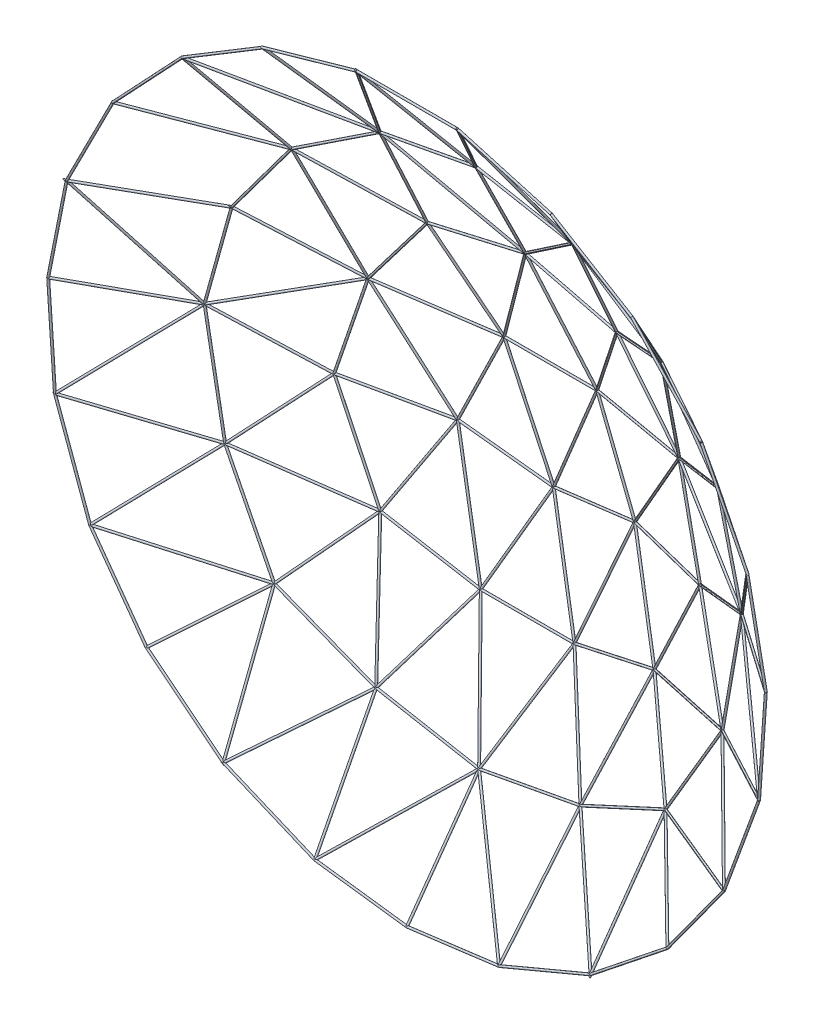
from build123d import *

# Parameters (mm, degrees)
SWEEP1_PROFILE_R  = 0.5
SWEEP2_PROFILE_R  = 0.5
SWEEP3_PROFILE_R  = 0.5
SWEEP4_PROFILE_R  = 0.5
SWEEP5_PROFILE_R  = 0.5
SWEEP6_PROFILE_R  = 0.5
SWEEP7_PROFILE_R  = 0.5
SWEEP8_PROFILE_R  = 0.5
SWEEP9_PROFILE_R  = 0.5
SWEEP10_PROFILE_R = 0.5
SWEEP11_PROFILE_R = 0.5
SWEEP12_PROFILE_R = 0.5
SWEEP13_PROFILE_R = 0.5
SWEEP14_PROFILE_R = 0.5
SWEEP15_PROFILE_R = 0.5
SWEEP16_PROFILE_R = 0.5
SWEEP17_PROFILE_R = 0.5
SWEEP18_PROFILE_R = 0.5
SWEEP19_PROFILE_R = 0.5
SWEEP20_PROFILE_R = 0.5
SWEEP21_PROFILE_R = 0.5
SWEEP22_PROFILE_R = 0.5
SWEEP23_PROFILE_R = 0.5
SWEEP24_PROFILE_R = 0.5
SWEEP25_PROFILE_R = 0.5
SWEEP26_PROFILE_R = 0.5
SWEEP27_PROFILE_R = 0.5
SWEEP28_PROFILE_R = 0.5
SWEEP29_PROFILE_R = 0.5
SWEEP30_PROFILE_R = 0.5
SWEEP31_PROFILE_R = 0.5
SWEEP32_PROFILE_R = 0.5
SWEEP33_PROFILE_R = 0.5
SWEEP34_PROFILE_R = 0.5
SWEEP35_PROFILE_R = 0.5
SWEEP36_PROFILE_R = 0.5
SWEEP37_PROFILE_R = 0.5
SWEEP38_PROFILE_R = 0.5
SWEEP39_PROFILE_R = 0.5
SWEEP40_PROFILE_R = 0.5
SWEEP41_PROFILE_R = 0.5
SWEEP42_PROFILE_R = 0.5
SWEEP43_PROFILE_R = 0.5
SWEEP44_PROFILE_R = 0.5
SWEEP45_PROFILE_R = 0.5
SWEEP46_PROFILE_R = 0.5
SWEEP47_PROFILE_R = 0.5
SWEEP48_PROFILE_R = 0.5
SWEEP49_PROFILE_R = 0.5
SWEEP50_PROFILE_R = 0.5
SWEEP51_PROFILE_R = 0.5
SWEEP52_PROFILE_R = 0.5
SWEEP53_PROFILE_R = 0.5
SWEEP54_PROFILE_R = 0.5
SWEEP55_PROFILE_R = 0.5
SWEEP56_PROFILE_R = 0.5
SWEEP57_PROFILE_R = 0.5
SWEEP58_PROFILE_R = 0.5
SWEEP59_PROFILE_R = 0.5
SWEEP60_PROFILE_R = 0.5
SWEEP61_PROFILE_R = 0.5
SWEEP62_PROFILE_R = 0.5
SWEEP63_PROFILE_R = 0.5
SWEEP64_PROFILE_R = 0.5
SWEEP65_PROFILE_R = 0.5
SWEEP66_PROFILE_R = 0.5
SWEEP67_PROFILE_R = 0.5
SWEEP68_PROFILE_R = 0.5
SWEEP69_PROFILE_R = 0.5
SWEEP70_PROFILE_R = 0.5
SWEEP71_PROFILE_R = 0.5
SWEEP72_PROFILE_R = 0.5
SWEEP73_PROFILE_R = 0.5
SWEEP74_PROFILE_R = 0.5


with BuildPart() as part:
    # Sweep1: sweep along a curve in space
    with BuildLine() as sweep1_path:
        Line((70.2, 160.3, 72.9), (24.6, 173.3, 72.9))
        Line((24.6, 173.3, 72.9), (-24.6, 173.3, 72.9))
    # Sweep1 profile (on start of the path) → Sweep1 (sweep)
    with BuildSketch(Plane(origin=(70.2, 160.3, 72.9), x_dir=(-0.2741639996416316, -0.9616829525891075, 0), z_dir=(-0.9616829525891075, 0.2741639996416316, 0))):
        Circle(SWEEP1_PROFILE_R)
    sweep(path=sweep1_path.line, transition=Transition.RIGHT)

    # Sweep2: sweep along a curve in space
    with BuildLine() as sweep2_path:
        Line((-24.6, 173.3, 72.9), (-70.2, 160.3, 72.9))
        Line((-70.2, 160.3, 72.9), (-46.9, 119.5, 39.2))
    # Sweep2 profile (on start of the path) → Sweep2 (sweep)
    with BuildSketch(Plane(origin=(-24.6, 173.3, 72.9), x_dir=(0.2741639996416316, -0.9616829525891075, 0), z_dir=(-0.9616829525891075, -0.2741639996416316, 0))):
        Circle(SWEEP2_PROFILE_R)
    sweep(path=sweep2_path.line, transition=Transition.RIGHT)

    # Sweep3: sweep along a curve in space
    with BuildLine() as sweep3_path:
        Line((-46.9, 119.5, 39.2), (-24.6, 173.3, 72.9))
        Line((-24.6, 173.3, 72.9), (0, 128.4, 39.3))
    # Sweep3 profile (on start of the path) → Sweep3 (sweep)
    with BuildSketch(Plane(origin=(-46.9, 119.5, 39.2), x_dir=(0, -0.5308482294262415, 0.8474669063243854), z_dir=(0.3314205781108869, 0.7995707220791802, 0.5008463444994122))):
        Circle(SWEEP3_PROFILE_R)
    sweep(path=sweep3_path.line, transition=Transition.RIGHT)

    # Sweep4: sweep along a curve in space
    with BuildLine() as sweep4_path:
        Line((0, 128.4, 39.3), (46.9, 119.5, 39.2))
        Line((46.9, 119.5, 39.2), (109.4, 136.6, 72.9))
    # Sweep4 profile (on start of the path) → Sweep4 (sweep)
    with BuildSketch(Plane(origin=(0, 128.4, 39.3), x_dir=(0.1864382404169094, 0.9824666826464127, 0), z_dir=(0.9824645270056661, -0.18643783135075492, -0.002094807093828891))):
        Circle(SWEEP4_PROFILE_R)
    sweep(path=sweep4_path.line, transition=Transition.RIGHT)

    # Sweep5: sweep along a curve in space
    with BuildLine() as sweep5_path:
        Line((109.4, 136.6, 72.9), (90, 90.9, 39))
        Line((90, 90.9, 39), (118.3, 52.6, 39.9))
    # Sweep5 profile (on start of the path) → Sweep5 (sweep)
    with BuildSketch(Plane(origin=(109.4, 136.6, 72.9), x_dir=(0, 0.5957737931269127, -0.8031522815899677), z_dir=(-0.322703778656751, -0.7601836435367798, -0.5638999018795807))):
        Circle(SWEEP5_PROFILE_R)
    sweep(path=sweep5_path.line, transition=Transition.RIGHT)

    # Sweep6: sweep along a curve in space
    with BuildLine() as sweep6_path:
        Line((118.3, 52.6, 39.9), (75.7, 32, 16.1))
        Line((75.7, 32, 16.1), (130.7, 6, 40.7))
    # Sweep6 profile (on start of the path) → Sweep6 (sweep)
    with BuildSketch(Plane(origin=(118.3, 52.6, 39.9), x_dir=(0.48772949518530323, 0, -0.8729948107098284), z_dir=(-0.8042662020819282, -0.38891745922271653, -0.44933182182042003))):
        Circle(SWEEP6_PROFILE_R)
    sweep(path=sweep6_path.line, transition=Transition.RIGHT)

    # Sweep7: sweep along a curve in space
    with BuildLine() as sweep7_path:
        Line((130.7, 6, 40.7), (171.3, -36, 72.9))
        Line((171.3, -36, 72.9), (154.2, -82.8, 72.9))
    # Sweep7 profile (on start of the path) → Sweep7 (sweep)
    with BuildSketch(Plane(origin=(130.7, 6, 40.7), x_dir=(-0.718988376049112, -0.695022096847475, 0), z_dir=(0.6086744462336146, -0.6296632202416703, 0.48274180218528057))):
        Circle(SWEEP7_PROFILE_R)
    sweep(path=sweep7_path.line, transition=Transition.RIGHT)

    # Sweep8: sweep along a curve in space
    with BuildLine() as sweep8_path:
        Line((154.2, -82.8, 72.9), (126.7, -120.7, 72.9))
        Line((154.2, -82.8, 72.9), (95.2, -93.3, 42.3))
    # Sweep8 profile (on start of the path) → Sweep8 (sweep)
    with BuildSketch(Plane(origin=(95.2, -93.3, 42.3), x_dir=(-0.46040499781355465, 0, 0.8877089827124094), z_dir=(0.8768342519652249, 0.1560467736548281, 0.4547648832226421))):
        Circle(SWEEP8_PROFILE_R)
    sweep(path=sweep8_path.line, transition=Transition.RIGHT)

    # Sweep9: sweep along a curve in space
    with BuildLine() as sweep9_path:
        Line((95.2, -93.3, 42.3), (66.7, -60.1, 19.2))
        Line((66.7, -60.1, 19.2), (121, -48.1, 40.4))
    # Sweep9 profile (on start of the path) → Sweep9 (sweep)
    with BuildSketch(Plane(origin=(95.2, -93.3, 42.3), x_dir=(0.7587724128401083, 0.6513558363235875, 0), z_dir=(-0.5760103446642665, 0.6710015243106539, -0.4668715425173526))):
        Circle(SWEEP9_PROFILE_R)
    sweep(path=sweep9_path.line, transition=Transition.RIGHT)

    # Sweep10: sweep along a curve in space
    with BuildLine() as sweep10_path:
        Line((121, -48.1, 40.4), (89, -13.2, 19.3))
        Line((89, -13.2, 19.3), (75.7, 32, 16.1))
    # Sweep10 profile (on start of the path) → Sweep10 (sweep)
    with BuildSketch(Plane(origin=(121, -48.1, 40.4), x_dir=(0.7370664686334993, 0.6758202577728363, 0), z_dir=(-0.6173029703937462, 0.6732460520856792, -0.4070341461033763))):
        Circle(SWEEP10_PROFILE_R)
    sweep(path=sweep10_path.line, transition=Transition.RIGHT)

    # Sweep11: sweep along a curve in space
    with BuildLine() as sweep11_path:
        Line((75.7, 32, 16.1), (43.1, -16.8, 5.1))
        Line((43.1, -16.8, 5.1), (66.7, -60.1, 19.2))
    # Sweep11 profile (on start of the path) → Sweep11 (sweep)
    with BuildSketch(Plane(origin=(75.7, 32, 16.1), x_dir=(-0.8315256316094289, 0.5554863850505611, 0), z_dir=(-0.5459786384308439, -0.8172931765467847, -0.18422592094292278))):
        Circle(SWEEP11_PROFILE_R)
    sweep(path=sweep11_path.line, transition=Transition.RIGHT)

    # Sweep12: sweep along a curve in space
    with BuildLine() as sweep12_path:
        Line((66.7, -60.1, 19.2), (22.8, -73.6, 14.2))
        Line((22.8, -73.6, 14.2), (49.7, -116.5, 38.2))
    # Sweep12 profile (on start of the path) → Sweep12 (sweep)
    with BuildSketch(Plane(origin=(66.7, -60.1, 19.2), x_dir=(0.293932846991094, -0.9558260728080765, 0), z_dir=(-0.9502119984175122, -0.2922064232035629, -0.10822460118650479))):
        Circle(SWEEP12_PROFILE_R)
    sweep(path=sweep12_path.line, transition=Transition.RIGHT)

    # Sweep13: sweep along a curve in space
    with BuildLine() as sweep13_path:
        Line((49.7, -116.5, 38.2), (44.8, -169.2, 72.9))
        Line((44.8, -169.2, 72.9), (0, -175, 72.9))
    # Sweep13 profile (on start of the path) → Sweep13 (sweep)
    with BuildSketch(Plane(origin=(49.7, -116.5, 38.2), x_dir=(0, -0.5499366446305571, -0.8352063738337275), z_dir=(-0.07742365604684504, -0.8326993211568832, 0.5482858907807184))):
        Circle(SWEEP13_PROFILE_R)
    sweep(path=sweep13_path.line, transition=Transition.RIGHT)

    # Sweep14: sweep along a curve in space
    with BuildLine() as sweep14_path:
        Line((0, -175, 72.9), (0, -126.1, 37.8))
        Line((0, -126.1, 37.8), (49.7, -116.5, 38.2))
    # Sweep14 profile (on start of the path) → Sweep14 (sweep)
    with BuildSketch(Plane(origin=(0, -175, 72.9), x_dir=(0, 0.5831224527684974, 0.8123842718056842), z_dir=(0, 0.8123842718056842, -0.5831224527684974))):
        Circle(SWEEP14_PROFILE_R)
    sweep(path=sweep14_path.line, transition=Transition.RIGHT)

    # Sweep15: sweep along a curve in space
    with BuildLine() as sweep15_path:
        Line((49.7, -116.5, 38.2), (89.3, -150.5, 72.9))
        Line((89.3, -150.5, 72.9), (95.2, -93.3, 42.3))
    # Sweep15 profile (on start of the path) → Sweep15 (sweep)
    with BuildSketch(Plane(origin=(49.7, -116.5, 38.2), x_dir=(-0.6590422824772967, 0, 0.7521058900893645), z_dir=(0.6318232837371024, -0.5424745365419565, 0.5536431299413499))):
        Circle(SWEEP15_PROFILE_R)
    sweep(path=sweep15_path.line, transition=Transition.RIGHT)

    # Sweep16: sweep along a curve in space
    with BuildLine() as sweep16_path:
        Line((95.2, -93.3, 42.3), (49.7, -116.5, 38.2))
        Line((49.7, -116.5, 38.2), (66.7, -60.1, 19.2))
    # Sweep16 profile (on start of the path) → Sweep16 (sweep)
    with BuildSketch(Plane(origin=(95.2, -93.3, 42.3), x_dir=(0.4542483901231364, -0.890875075457013, 0), z_dir=(-0.8880183239286837, -0.4527917607724278, -0.08001923358478251))):
        Circle(SWEEP16_PROFILE_R)
    sweep(path=sweep16_path.line, transition=Transition.RIGHT)

    # Sweep17: sweep along a curve in space
    with BuildLine() as sweep17_path:
        Line((66.7, -60.1, 19.2), (89, -13.2, 19.3))
        Line((89, -13.2, 19.3), (130.7, 6, 40.7))
    # Sweep17 profile (on start of the path) → Sweep17 (sweep)
    with BuildSketch(Plane(origin=(66.7, -60.1, 19.2), x_dir=(0.9031095214958049, -0.4294102842080268, 0), z_dir=(0.429409488091949, 0.9031078471530225, 0.0019256030856141476))):
        Circle(SWEEP17_PROFILE_R)
    sweep(path=sweep17_path.line, transition=Transition.RIGHT)

    # Sweep18: sweep along a curve in space
    with BuildLine() as sweep18_path:
        Line((130.7, 6, 40.7), (118.3, 52.6, 39.9))
        Line((130.7, 6, 40.7), (121, -48.1, 40.4))
    # Sweep18 profile (on start of the path) → Sweep18 (sweep)
    with BuildSketch(Plane(origin=(121, -48.1, 40.4), x_dir=(0.9843036385612428, -0.17648327715423429, 0), z_dir=(0.1764806482787259, 0.9842889764823765, 0.005458164379754477))):
        Circle(SWEEP18_PROFILE_R)
    sweep(path=sweep18_path.line, transition=Transition.RIGHT)

    # Sweep19: sweep along a curve in space
    with BuildLine() as sweep19_path:
        Line((121, -48.1, 40.4), (171.3, -36, 72.9))
        Line((171.3, -36, 72.9), (174.6, 11.2, 72.9))
    # Sweep19 profile (on start of the path) → Sweep19 (sweep)
    with BuildSketch(Plane(origin=(121, -48.1, 40.4), x_dir=(-0.5426972625369433, 0, 0.8399283786341), z_dir=(0.8232913130617963, 0.19804820850989518, 0.531947667485256))):
        Circle(SWEEP19_PROFILE_R)
    sweep(path=sweep19_path.line, transition=Transition.RIGHT)

    # Sweep20: sweep along a curve in space
    with BuildLine() as sweep20_path:
        Line((174.6, 11.2, 72.9), (130.7, 6, 40.7))
        Line((130.7, 6, 40.7), (165.6, 56.6, 72.9))
    # Sweep20 profile (on start of the path) → Sweep20 (sweep)
    with BuildSketch(Plane(origin=(174.6, 11.2, 72.9), x_dir=(0.5914432899526433, 0, -0.8063465971714606), z_dir=(-0.8026935621323736, -0.09507987524119235, -0.5887638428396912))):
        Circle(SWEEP20_PROFILE_R)
    sweep(path=sweep20_path.line, transition=Transition.RIGHT)

    # Sweep21: sweep along a curve in space
    with BuildLine() as sweep21_path:
        Line((121, -48.1, 40.4), (95.2, -93.3, 42.3))
        Line((95.2, -93.3, 42.3), (126.7, -120.7, 72.9))
    # Sweep21 profile (on start of the path) → Sweep21 (sweep)
    with BuildSketch(Plane(origin=(121, -48.1, 40.4), x_dir=(-0.868479525327704, 0.49572503879324686, 0), z_dir=(-0.4953950292338643, -0.8679013690453748, 0.0364825796722613))):
        Circle(SWEEP21_PROFILE_R)
    sweep(path=sweep21_path.line, transition=Transition.RIGHT)

    # Sweep22: sweep along a curve in space
    with BuildLine() as sweep22_path:
        Line((126.7, -120.7, 72.9), (89.3, -150.5, 72.9))
        Line((89.3, -150.5, 72.9), (44.8, -169.2, 72.9))
    # Sweep22 profile (on start of the path) → Sweep22 (sweep)
    with BuildSketch(Plane(origin=(126.7, -120.7, 72.9), x_dir=(0.6231637359515897, -0.7820914001540085, 0), z_dir=(-0.7820914001540085, -0.6231637359515897, 0))):
        Circle(SWEEP22_PROFILE_R)
    sweep(path=sweep22_path.line, transition=Transition.RIGHT)

    # Sweep23: sweep along a curve in space
    with BuildLine() as sweep23_path:
        Line((44.8, -169.2, 72.9), (0, -126.1, 37.8))
        Line((0, -126.1, 37.8), (22.8, -73.6, 14.2))
    # Sweep23 profile (on start of the path) → Sweep23 (sweep)
    with BuildSketch(Plane(origin=(44.8, -169.2, 72.9), x_dir=(-0.6933015736679883, -0.7206475754135936, 0), z_dir=(-0.6275309969389807, 0.6037184367872783, -0.4916593301910319))):
        Circle(SWEEP23_PROFILE_R)
    sweep(path=sweep23_path.line, transition=Transition.RIGHT)

    # Sweep24: sweep along a curve in space
    with BuildLine() as sweep24_path:
        Line((22.8, -73.6, 14.2), (-22.8, -73.6, 14.2))
        Line((-22.8, -73.6, 14.2), (-43.1, -16.8, 5.1))
    # Sweep24 profile (on start of the path) → Sweep24 (sweep)
    with BuildSketch(Plane(origin=(22.8, -73.6, 14.2), x_dir=(0, 0, -1), z_dir=(-1, 0, 0))):
        Circle(SWEEP24_PROFILE_R)
    sweep(path=sweep24_path.line, transition=Transition.RIGHT)

    # Sweep25: sweep along a curve in space
    with BuildLine() as sweep25_path:
        Line((-43.1, -16.8, 5.1), (-66.7, -60.1, 19.2))
        Line((-66.7, -60.1, 19.2), (-49.7, -116.5, 38.2))
    # Sweep25 profile (on start of the path) → Sweep25 (sweep)
    with BuildSketch(Plane(origin=(-43.1, -16.8, 5.1), x_dir=(-0.8780505203260427, 0.47856795103220784, 0), z_dir=(-0.4601290386199045, -0.844219803908554, 0.27490760358223115))):
        Circle(SWEEP25_PROFILE_R)
    sweep(path=sweep25_path.line, transition=Transition.RIGHT)

    # Sweep26: sweep along a curve in space
    with BuildLine() as sweep26_path:
        Line((-49.7, -116.5, 38.2), (0, -126.1, 37.8))
        Line((0, -126.1, 37.8), (-44.8, -169.2, 72.9))
    # Sweep26 profile (on start of the path) → Sweep26 (sweep)
    with BuildSketch(Plane(origin=(-49.7, -116.5, 38.2), x_dir=(0.18965333416452992, 0.9818511154142858, 0), z_dir=(0.9818204609462534, -0.1896474129795579, -0.007901975540814888))):
        Circle(SWEEP26_PROFILE_R)
    sweep(path=sweep26_path.line, transition=Transition.RIGHT)

    # Sweep27: sweep along a curve in space
    with BuildLine() as sweep27_path:
        Line((-44.8, -169.2, 72.9), (-49.7, -116.5, 38.2))
        Line((-49.7, -116.5, 38.2), (-22.8, -73.6, 14.2))
    # Sweep27 profile (on start of the path) → Sweep27 (sweep)
    with BuildSketch(Plane(origin=(-44.8, -169.2, 72.9), x_dir=(0, 0.5499366446305571, 0.8352063738337275), z_dir=(-0.07742365604684504, 0.8326993211568832, -0.5482858907807184))):
        Circle(SWEEP27_PROFILE_R)
    sweep(path=sweep27_path.line, transition=Transition.RIGHT)

    # Sweep28: sweep along a curve in space
    with BuildLine() as sweep28_path:
        Line((-22.8, -73.6, 14.2), (0, -25.4, 1.5))
        Line((0, -25.4, 1.5), (43.1, -16.8, 5.1))
    # Sweep28 profile (on start of the path) → Sweep28 (sweep)
    with BuildSketch(Plane(origin=(-22.8, -73.6, 14.2), x_dir=(0.9039668368026096, -0.4276025701057987, 0), z_dir=(0.4159662918364596, 0.879367336250761, -0.23170052220715076))):
        Circle(SWEEP28_PROFILE_R)
    sweep(path=sweep28_path.line, transition=Transition.RIGHT)

    # Sweep29: sweep along a curve in space
    with BuildLine() as sweep29_path:
        Line((43.1, -16.8, 5.1), (22.8, -73.6, 14.2))
        Line((22.8, -73.6, 14.2), (0, -25.4, 1.5))
    # Sweep29 profile (on start of the path) → Sweep29 (sweep)
    with BuildSketch(Plane(origin=(43.1, -16.8, 5.1), x_dir=(-0.9416668716903649, 0.3365464347766622, 0), z_dir=(-0.332780624986659, -0.9311300245932133, 0.1491775215457437))):
        Circle(SWEEP29_PROFILE_R)
    sweep(path=sweep29_path.line, transition=Transition.RIGHT)

    # Sweep30: sweep along a curve in space
    with BuildLine() as sweep30_path:
        Line((0, -25.4, 1.5), (-22.6, 27.4, 3))
        Line((-22.6, 27.4, 3), (-43.1, -16.8, 5.1))
    # Sweep30 profile (on start of the path) → Sweep30 (sweep)
    with BuildSketch(Plane(origin=(0, -25.4, 1.5), x_dir=(0.9193250524776412, 0.39349898079535395, 0), z_dir=(-0.3933648450977043, 0.9190116735026013, 0.026108286179051175))):
        Circle(SWEEP30_PROFILE_R)
    sweep(path=sweep30_path.line, transition=Transition.RIGHT)

    # Sweep31: sweep along a curve in space
    with BuildLine() as sweep31_path:
        Line((-43.1, -16.8, 5.1), (0, -25.4, 1.5))
        Line((0, -25.4, 1.5), (22.6, 27.4, 3))
    # Sweep31 profile (on start of the path) → Sweep31 (sweep)
    with BuildSketch(Plane(origin=(-43.1, -16.8, 5.1), x_dir=(0.1956785517671682, 0.980668090833134, 0), z_dir=(0.9773946247566413, -0.19502537756164995, -0.08163853014208607))):
        Circle(SWEEP31_PROFILE_R)
    sweep(path=sweep31_path.line, transition=Transition.RIGHT)

    # Sweep32: sweep along a curve in space
    with BuildLine() as sweep32_path:
        Line((22.6, 27.4, 3), (75.7, 32, 16.1))
        Line((75.7, 32, 16.1), (46.1, 70.6, 16.9))
    # Sweep32 profile (on start of the path) → Sweep32 (sweep)
    with BuildSketch(Plane(origin=(22.6, 27.4, 3), x_dir=(-0.23952294217582776, 0, 0.9708907045447676), z_dir=(0.9674747590628802, 0.08381137272484455, 0.23868021362944875))):
        Circle(SWEEP32_PROFILE_R)
    sweep(path=sweep32_path.line, transition=Transition.RIGHT)

    # Sweep33: sweep along a curve in space
    with BuildLine() as sweep33_path:
        Line((46.1, 70.6, 16.9), (0, 80, 15.3))
        Line((46.1, 70.6, 16.9), (90, 90.9, 39))
    # Sweep33 profile (on start of the path) → Sweep33 (sweep)
    with BuildSketch(Plane(origin=(90, 90.9, 39), x_dir=(0.4496534866838584, 0, -0.8932030798833205), z_dir=(-0.8255570422115478, -0.38174961177436034, -0.41559933104499336))):
        Circle(SWEEP33_PROFILE_R)
    sweep(path=sweep33_path.line, transition=Transition.RIGHT)

    # Sweep34: sweep along a curve in space
    with BuildLine() as sweep34_path:
        Line((90, 90.9, 39), (143.1, 100.8, 72.9))
        Line((143.1, 100.8, 72.9), (118.3, 52.6, 39.9))
    # Sweep34 profile (on start of the path) → Sweep34 (sweep)
    with BuildSketch(Plane(origin=(90, 90.9, 39), x_dir=(-0.5381074402163571, 0, 0.8428762559141169), z_dir=(0.8326577177313902, 0.15524126940754743, 0.5315837406985713))):
        Circle(SWEEP34_PROFILE_R)
    sweep(path=sweep34_path.line, transition=Transition.RIGHT)

    # Sweep35: sweep along a curve in space
    with BuildLine() as sweep35_path:
        Line((118.3, 52.6, 39.9), (165.6, 56.6, 72.9))
        Line((165.6, 56.6, 72.9), (143.1, 100.8, 72.9))
    # Sweep35 profile (on start of the path) → Sweep35 (sweep)
    with BuildSketch(Plane(origin=(118.3, 52.6, 39.9), x_dir=(-0.5721815960240814, 0, 0.8201269543011831), z_dir=(0.8181615693089973, 0.06918913905361487, 0.5708103971923238))):
        Circle(SWEEP35_PROFILE_R)
    sweep(path=sweep35_path.line, transition=Transition.RIGHT)

    # Sweep36: sweep along a curve in space
    with BuildLine() as sweep36_path:
        Line((143.1, 100.8, 72.9), (109.4, 136.6, 72.9))
        Line((109.4, 136.6, 72.9), (70.2, 160.3, 72.9))
    # Sweep36 profile (on start of the path) → Sweep36 (sweep)
    with BuildSketch(Plane(origin=(143.1, 100.8, 72.9), x_dir=(0.7281402787689522, 0.6854281395115557, 0), z_dir=(-0.6854281395115557, 0.7281402787689522, 0))):
        Circle(SWEEP36_PROFILE_R)
    sweep(path=sweep36_path.line, transition=Transition.RIGHT)

    # Sweep37: sweep along a curve in space
    with BuildLine() as sweep37_path:
        Line((0, 80, 15.3), (-46.1, 70.6, 16.9))
        Line((-46.1, 70.6, 16.9), (-46.9, 119.5, 39.2))
    # Sweep37 profile (on start of the path) → Sweep37 (sweep)
    with BuildSketch(Plane(origin=(0, 80, 15.3), x_dir=(0.19979343950392453, -0.9798380384181826, 0), z_dir=(-0.979271936655653, -0.19967800877577319, 0.03398774617459967))):
        Circle(SWEEP37_PROFILE_R)
    sweep(path=sweep37_path.line, transition=Transition.RIGHT)

    # Sweep38: sweep along a curve in space
    with BuildLine() as sweep38_path:
        Line((-46.9, 119.5, 39.2), (0, 80, 15.3))
        Line((0, 80, 15.3), (46.9, 119.5, 39.2))
    # Sweep38 profile (on start of the path) → Sweep38 (sweep)
    with BuildSketch(Plane(origin=(-46.9, 119.5, 39.2), x_dir=(0.6441859650757294, 0.7648689053683977, 0), z_dir=(0.7126482798907372, -0.6002048412725826, -0.3631619166180942))):
        Circle(SWEEP38_PROFILE_R)
    sweep(path=sweep38_path.line, transition=Transition.RIGHT)

    # Sweep39: sweep along a curve in space
    with BuildLine() as sweep39_path:
        Line((46.9, 119.5, 39.2), (46.1, 70.6, 16.9))
        Line((46.1, 70.6, 16.9), (22.6, 27.4, 3))
    # Sweep39 profile (on start of the path) → Sweep39 (sweep)
    with BuildSketch(Plane(origin=(46.9, 119.5, 39.2), x_dir=(0, 0.4149241157255484, -0.9098560205820323), z_dir=(-0.014883521304027534, -0.9097552397086863, -0.41487815634976893))):
        Circle(SWEEP39_PROFILE_R)
    sweep(path=sweep39_path.line, transition=Transition.RIGHT)

    # Sweep40: sweep along a curve in space
    with BuildLine() as sweep40_path:
        Line((22.6, 27.4, 3), (43.1, -16.8, 5.1))
        Line((43.1, -16.8, 5.1), (89, -13.2, 19.3))
    # Sweep40 profile (on start of the path) → Sweep40 (sweep)
    with BuildSketch(Plane(origin=(22.6, 27.4, 3), x_dir=(-0.9071768809319928, -0.4207494583508111, 0), z_dir=(0.4203591867156991, -0.9063354172114096, 0.04306118498063259))):
        Circle(SWEEP40_PROFILE_R)
    sweep(path=sweep40_path.line, transition=Transition.RIGHT)

    # Sweep41: sweep along a curve in space
    with BuildLine() as sweep41_path:
        Line((75.7, 32, 16.1), (90, 90.9, 39))
        Line((90, 90.9, 39), (46.9, 119.5, 39.2))
    # Sweep41 profile (on start of the path) → Sweep41 (sweep)
    with BuildSketch(Plane(origin=(75.7, 32, 16.1), x_dir=(0, -0.36236989740921455, 0.9320343649520845), z_dir=(0.2207034543108249, 0.9090512908326983, 0.35343420305719514))):
        Circle(SWEEP41_PROFILE_R)
    sweep(path=sweep41_path.line, transition=Transition.RIGHT)

    # Sweep42: sweep along a curve in space
    with BuildLine() as sweep42_path:
        Line((46.9, 119.5, 39.2), (24.6, 173.3, 72.9))
        Line((24.6, 173.3, 72.9), (0, 128.4, 39.3))
    # Sweep42 profile (on start of the path) → Sweep42 (sweep)
    with BuildSketch(Plane(origin=(46.9, 119.5, 39.2), x_dir=(0, -0.5308482294262415, 0.8474669063243854), z_dir=(-0.3314205781108869, 0.7995707220791802, 0.5008463444994122))):
        Circle(SWEEP42_PROFILE_R)
    sweep(path=sweep42_path.line, transition=Transition.RIGHT)

    # Sweep43: sweep along a curve in space
    with BuildLine() as sweep43_path:
        Line((-75.7, 32, 16.1), (-89, -13.2, 19.3))
        Line((-75.7, 32, 16.1), (-22.6, 27.4, 3))
    # Sweep43 profile (on start of the path) → Sweep43 (sweep)
    with BuildSketch(Plane(origin=(-22.6, 27.4, 3), x_dir=(-0.23952294217582776, 0, -0.9708907045447676), z_dir=(-0.9674747590628802, 0.08381137272484455, 0.23868021362944875))):
        Circle(SWEEP43_PROFILE_R)
    sweep(path=sweep43_path.line, transition=Transition.RIGHT)

    # Sweep44: sweep along a curve in space
    with BuildLine() as sweep44_path:
        Line((-22.6, 27.4, 3), (22.6, 27.4, 3))
        Line((22.6, 27.4, 3), (0, 80, 15.3))
    # Sweep44 profile (on start of the path) → Sweep44 (sweep)
    with BuildSketch(Plane(origin=(-22.6, 27.4, 3), x_dir=(0, 0, 1), z_dir=(1, 0, 0))):
        Circle(SWEEP44_PROFILE_R)
    sweep(path=sweep44_path.line, transition=Transition.RIGHT)

    # Sweep45: sweep along a curve in space
    with BuildLine() as sweep45_path:
        Line((0, 80, 15.3), (-22.6, 27.4, 3))
        Line((-22.6, 27.4, 3), (-46.1, 70.6, 16.9))
    # Sweep45 profile (on start of the path) → Sweep45 (sweep)
    with BuildSketch(Plane(origin=(0, 80, 15.3), x_dir=(-0.9187832495054922, 0.3947623847685195, 0), z_dir=(-0.38595505106524336, -0.8982847648686637, -0.21005518265940237))):
        Circle(SWEEP45_PROFILE_R)
    sweep(path=sweep45_path.line, transition=Transition.RIGHT)

    # Sweep46: sweep along a curve in space
    with BuildLine() as sweep46_path:
        Line((-46.1, 70.6, 16.9), (-90, 90.9, 39))
        Line((-90, 90.9, 39), (-75.7, 32, 16.1))
    # Sweep46 profile (on start of the path) → Sweep46 (sweep)
    with BuildSketch(Plane(origin=(-46.1, 70.6, 16.9), x_dir=(-0.4496534866838584, 0, -0.8932030798833205), z_dir=(-0.8255570422115478, 0.38174961177436034, 0.41559933104499336))):
        Circle(SWEEP46_PROFILE_R)
    sweep(path=sweep46_path.line, transition=Transition.RIGHT)

    # Sweep47: sweep along a curve in space
    with BuildLine() as sweep47_path:
        Line((-75.7, 32, 16.1), (-43.1, -16.8, 5.1))
        Line((-43.1, -16.8, 5.1), (-89, -13.2, 19.3))
    # Sweep47 profile (on start of the path) → Sweep47 (sweep)
    with BuildSketch(Plane(origin=(-75.7, 32, 16.1), x_dir=(-0.8315256316094289, -0.5554863850505611, 0), z_dir=(0.5459786384308439, -0.8172931765467847, -0.18422592094292278))):
        Circle(SWEEP47_PROFILE_R)
    sweep(path=sweep47_path.line, transition=Transition.RIGHT)

    # Sweep48: sweep along a curve in space
    with BuildLine() as sweep48_path:
        Line((-89, -13.2, 19.3), (-66.7, -60.1, 19.2))
        Line((-66.7, -60.1, 19.2), (-95.2, -93.3, 42.3))
    # Sweep48 profile (on start of the path) → Sweep48 (sweep)
    with BuildSketch(Plane(origin=(-89, -13.2, 19.3), x_dir=(-0.9031095214958049, -0.4294102842080268, 0), z_dir=(0.429409488091949, -0.9031078471530225, -0.0019256030856141476))):
        Circle(SWEEP48_PROFILE_R)
    sweep(path=sweep48_path.line, transition=Transition.RIGHT)

    # Sweep49: sweep along a curve in space
    with BuildLine() as sweep49_path:
        Line((-95.2, -93.3, 42.3), (-89.3, -150.5, 72.9))
        Line((-89.3, -150.5, 72.9), (-126.7, -120.7, 72.9))
    # Sweep49 profile (on start of the path) → Sweep49 (sweep)
    with BuildSketch(Plane(origin=(-95.2, -93.3, 42.3), x_dir=(0, -0.4717079985656813, -0.8817548208482668), z_dir=(0.09057638509267417, -0.8781303775086391, 0.46976904810776854))):
        Circle(SWEEP49_PROFILE_R)
    sweep(path=sweep49_path.line, transition=Transition.RIGHT)

    # Sweep50: sweep along a curve in space
    with BuildLine() as sweep50_path:
        Line((-126.7, -120.7, 72.9), (-95.2, -93.3, 42.3))
        Line((-95.2, -93.3, 42.3), (-49.7, -116.5, 38.2))
    # Sweep50 profile (on start of the path) → Sweep50 (sweep)
    with BuildSketch(Plane(origin=(-126.7, -120.7, 72.9), x_dir=(0.6967856842632492, 0, 0.7172793808592268), z_dir=(0.6085471160100789, 0.5293393961484497, -0.5911600555526483))):
        Circle(SWEEP50_PROFILE_R)
    sweep(path=sweep50_path.line, transition=Transition.RIGHT)

    # Sweep51: sweep along a curve in space
    with BuildLine() as sweep51_path:
        Line((-49.7, -116.5, 38.2), (-89.3, -150.5, 72.9))
        Line((-89.3, -150.5, 72.9), (-44.8, -169.2, 72.9))
    # Sweep51 profile (on start of the path) → Sweep51 (sweep)
    with BuildSketch(Plane(origin=(-49.7, -116.5, 38.2), x_dir=(-0.6590422824772967, 0, -0.7521058900893645), z_dir=(-0.6318232837371024, -0.5424745365419565, 0.5536431299413499))):
        Circle(SWEEP51_PROFILE_R)
    sweep(path=sweep51_path.line, transition=Transition.RIGHT)

    # Sweep52: sweep along a curve in space
    with BuildLine() as sweep52_path:
        Line((-22.8, -73.6, 14.2), (-66.7, -60.1, 19.2))
        Line((-66.7, -60.1, 19.2), (-121, -48.1, 40.4))
    # Sweep52 profile (on start of the path) → Sweep52 (sweep)
    with BuildSketch(Plane(origin=(-22.8, -73.6, 14.2), x_dir=(-0.293932846991094, -0.9558260728080765, 0), z_dir=(-0.9502119984175122, 0.2922064232035629, 0.10822460118650479))):
        Circle(SWEEP52_PROFILE_R)
    sweep(path=sweep52_path.line, transition=Transition.RIGHT)

    # Sweep53: sweep along a curve in space
    with BuildLine() as sweep53_path:
        Line((-121, -48.1, 40.4), (-171.3, -36, 72.9))
        Line((-171.3, -36, 72.9), (-154.2, -82.8, 72.9))
    # Sweep53 profile (on start of the path) → Sweep53 (sweep)
    with BuildSketch(Plane(origin=(-121, -48.1, 40.4), x_dir=(-0.5426972625369433, 0, -0.8399283786341), z_dir=(-0.8232913130617963, 0.19804820850989518, 0.531947667485256))):
        Circle(SWEEP53_PROFILE_R)
    sweep(path=sweep53_path.line, transition=Transition.RIGHT)

    # Sweep54: sweep along a curve in space
    with BuildLine() as sweep54_path:
        Line((-171.3, -36, 72.9), (-174.6, 11.2, 72.9))
        Line((-174.6, 11.2, 72.9), (-165.6, 56.6, 72.9))
    # Sweep54 profile (on start of the path) → Sweep54 (sweep)
    with BuildSketch(Plane(origin=(-171.3, -36, 72.9), x_dir=(0.9975648524962569, 0.06974500028045828, 0), z_dir=(-0.06974500028045828, 0.9975648524962569, 0))):
        Circle(SWEEP54_PROFILE_R)
    sweep(path=sweep54_path.line, transition=Transition.RIGHT)

    # Sweep55: sweep along a curve in space
    with BuildLine() as sweep55_path:
        Line((-165.6, 56.6, 72.9), (-143.1, 100.8, 72.9))
        Line((-143.1, 100.8, 72.9), (-90, 90.9, 39))
    # Sweep55 profile (on start of the path) → Sweep55 (sweep)
    with BuildSketch(Plane(origin=(-165.6, 56.6, 72.9), x_dir=(0.8911779365254942, -0.4536539269643352, 0), z_dir=(0.4536539269643352, 0.8911779365254942, 0))):
        Circle(SWEEP55_PROFILE_R)
    sweep(path=sweep55_path.line, transition=Transition.RIGHT)

    # Sweep56: sweep along a curve in space
    with BuildLine() as sweep56_path:
        Line((-90, 90.9, 39), (-46.9, 119.5, 39.2))
        Line((-46.9, 119.5, 39.2), (-109.4, 136.6, 72.9))
    # Sweep56 profile (on start of the path) → Sweep56 (sweep)
    with BuildSketch(Plane(origin=(-90, 90.9, 39), x_dir=(-0.5529143662384965, 0.8332380833873844, 0), z_dir=(0.8332318549669673, 0.5529102332263404, 0.0038665051274568425))):
        Circle(SWEEP56_PROFILE_R)
    sweep(path=sweep56_path.line, transition=Transition.RIGHT)

    # Sweep57: sweep along a curve in space
    with BuildLine() as sweep57_path:
        Line((-109.4, 136.6, 72.9), (-90, 90.9, 39))
        Line((-90, 90.9, 39), (-118.3, 52.6, 39.9))
    # Sweep57 profile (on start of the path) → Sweep57 (sweep)
    with BuildSketch(Plane(origin=(-109.4, 136.6, 72.9), x_dir=(0, 0.5957737931269127, -0.8031522815899677), z_dir=(0.322703778656751, -0.7601836435367798, -0.5638999018795807))):
        Circle(SWEEP57_PROFILE_R)
    sweep(path=sweep57_path.line, transition=Transition.RIGHT)

    # Sweep58: sweep along a curve in space
    with BuildLine() as sweep58_path:
        Line((-118.3, 52.6, 39.9), (-130.7, 6, 40.7))
        Line((-118.3, 52.6, 39.9), (-75.7, 32, 16.1))
    # Sweep58 profile (on start of the path) → Sweep58 (sweep)
    with BuildSketch(Plane(origin=(-75.7, 32, 16.1), x_dir=(-0.48772949518530323, 0, -0.8729948107098284), z_dir=(-0.8042662020819282, 0.38891745922271653, 0.44933182182042003))):
        Circle(SWEEP58_PROFILE_R)
    sweep(path=sweep58_path.line, transition=Transition.RIGHT)

    # Sweep59: sweep along a curve in space
    with BuildLine() as sweep59_path:
        Line((-75.7, 32, 16.1), (-130.7, 6, 40.7))
        Line((-130.7, 6, 40.7), (-174.6, 11.2, 72.9))
    # Sweep59 profile (on start of the path) → Sweep59 (sweep)
    with BuildSketch(Plane(origin=(-75.7, 32, 16.1), x_dir=(0.4273796168934162, -0.9040722665053037, 0), z_dir=(-0.8381420081043305, -0.39621258564931977, 0.3748780618066641))):
        Circle(SWEEP59_PROFILE_R)
    sweep(path=sweep59_path.line, transition=Transition.RIGHT)

    # Sweep60: sweep along a curve in space
    with BuildLine() as sweep60_path:
        Line((-171.3, -36, 72.9), (-130.7, 6, 40.7))
        Line((-130.7, 6, 40.7), (-121, -48.1, 40.4))
    # Sweep60 profile (on start of the path) → Sweep60 (sweep)
    with BuildSketch(Plane(origin=(-171.3, -36, 72.9), x_dir=(0.718988376049112, -0.695022096847475, 0), z_dir=(0.6086744462336146, 0.6296632202416703, -0.48274180218528057))):
        Circle(SWEEP60_PROFILE_R)
    sweep(path=sweep60_path.line, transition=Transition.RIGHT)

    # Sweep61: sweep along a curve in space
    with BuildLine() as sweep61_path:
        Line((-121, -48.1, 40.4), (-95.2, -93.3, 42.3))
        Line((-95.2, -93.3, 42.3), (-154.2, -82.8, 72.9))
    # Sweep61 profile (on start of the path) → Sweep61 (sweep)
    with BuildSketch(Plane(origin=(-121, -48.1, 40.4), x_dir=(-0.868479525327704, -0.49572503879324686, 0), z_dir=(0.4953950292338643, -0.8679013690453748, 0.0364825796722613))):
        Circle(SWEEP61_PROFILE_R)
    sweep(path=sweep61_path.line, transition=Transition.RIGHT)

    # Sweep62: sweep along a curve in space
    with BuildLine() as sweep62_path:
        Line((-154.2, -82.8, 72.9), (-126.7, -120.7, 72.9))
        Line((-154.2, -82.8, 72.9), (-121, -48.1, 40.4))
    # Sweep62 profile (on start of the path) → Sweep62 (sweep)
    with BuildSketch(Plane(origin=(-121, -48.1, 40.4), x_dir=(-0.7225514063897148, 0.691317195738863, 0), z_dir=(-0.5725346440261192, -0.5984021731236845, 0.560463130447255))):
        Circle(SWEEP62_PROFILE_R)
    sweep(path=sweep62_path.line, transition=Transition.RIGHT)

    # Sweep63: sweep along a curve in space
    with BuildLine() as sweep63_path:
        Line((-121, -48.1, 40.4), (-89, -13.2, 19.3))
        Line((-89, -13.2, 19.3), (-130.7, 6, 40.7))
    # Sweep63 profile (on start of the path) → Sweep63 (sweep)
    with BuildSketch(Plane(origin=(-121, -48.1, 40.4), x_dir=(0.7370664686334993, -0.6758202577728363, 0), z_dir=(0.6173029703937462, 0.6732460520856792, -0.4070341461033763))):
        Circle(SWEEP63_PROFILE_R)
    sweep(path=sweep63_path.line, transition=Transition.RIGHT)

    # Sweep64: sweep along a curve in space
    with BuildLine() as sweep64_path:
        Line((-130.7, 6, 40.7), (-165.6, 56.6, 72.9))
        Line((-165.6, 56.6, 72.9), (-118.3, 52.6, 39.9))
    # Sweep64 profile (on start of the path) → Sweep64 (sweep)
    with BuildSketch(Plane(origin=(-130.7, 6, 40.7), x_dir=(0.8231865666503426, 0.5677709718596234, 0), z_dir=(-0.5029418915638042, 0.7291936880552581, 0.46403234694425527))):
        Circle(SWEEP64_PROFILE_R)
    sweep(path=sweep64_path.line, transition=Transition.RIGHT)

    # Sweep65: sweep along a curve in space
    with BuildLine() as sweep65_path:
        Line((-118.3, 52.6, 39.9), (-143.1, 100.8, 72.9))
        Line((-143.1, 100.8, 72.9), (-109.4, 136.6, 72.9))
    # Sweep65 profile (on start of the path) → Sweep65 (sweep)
    with BuildSketch(Plane(origin=(-118.3, 52.6, 39.9), x_dir=(0, -0.5649293716432666, 0.8251392640365285), z_dir=(-0.3907920931929197, 0.7595233424152713, 0.5200056078776756))):
        Circle(SWEEP65_PROFILE_R)
    sweep(path=sweep65_path.line, transition=Transition.RIGHT)

    # Sweep66: sweep along a curve in space
    with BuildLine() as sweep66_path:
        Line((-109.4, 136.6, 72.9), (-70.2, 160.3, 72.9))
    # Sweep66 profile (on start of the path) → Sweep66 (sweep)
    with BuildSketch(Plane(origin=(-109.4, 136.6, 72.9), x_dir=(-0.5173821617772882, 0.8557544616738262, 0), z_dir=(0.8557544616738262, 0.5173821617772882, 0))):
        Circle(SWEEP66_PROFILE_R)
    sweep(path=sweep66_path.line)

    # Sweep67: sweep along a curve in space
    with BuildLine() as sweep67_path:
        Line((165.6, 56.6, 72.9), (174.6, 11.2, 72.9))
    # Sweep67 profile (on start of the path) → Sweep67 (sweep)
    with BuildSketch(Plane(origin=(165.6, 56.6, 72.9), x_dir=(-0.9809116669700074, -0.19445385468568432, 0), z_dir=(0.19445385468568432, -0.9809116669700074, 0))):
        Circle(SWEEP67_PROFILE_R)
    sweep(path=sweep67_path.line)

    # Sweep68: sweep along a curve in space
    with BuildLine() as sweep68_path:
        Line((154.2, -82.8, 72.9), (121, -48.1, 40.4))
    # Sweep68 profile (on start of the path) → Sweep68 (sweep)
    with BuildSketch(Plane(origin=(154.2, -82.8, 72.9), x_dir=(0.7225514063897148, 0.691317195738863, 0), z_dir=(-0.5725346440261192, 0.5984021731236845, -0.560463130447255))):
        Circle(SWEEP68_PROFILE_R)
    sweep(path=sweep68_path.line)

    # Sweep69: sweep along a curve in space
    with BuildLine() as sweep69_path:
        Line((0, 128.4, 39.3), (0, 80, 15.3))
    # Sweep69 profile (on start of the path) → Sweep69 (sweep)
    with BuildSketch(Plane(origin=(0, 128.4, 39.3), x_dir=(0, 0.4442494805947632, -0.8959031191994384), z_dir=(0, -0.8959031191994384, -0.4442494805947632))):
        Circle(SWEEP69_PROFILE_R)
    sweep(path=sweep69_path.line)

    # Sweep70: sweep along a curve in space
    with BuildLine() as sweep70_path:
        Line((70.2, 160.3, 72.9), (46.9, 119.5, 39.2))
    # Sweep70 profile (on start of the path) → Sweep70 (sweep)
    with BuildSketch(Plane(origin=(70.2, 160.3, 72.9), x_dir=(0, 0.6368326104902324, -0.7710020922255632), z_dir=(-0.40297067512089274, -0.7056310534305762, -0.5828374142306475))):
        Circle(SWEEP70_PROFILE_R)
    sweep(path=sweep70_path.line)

    # Sweep71: sweep along a curve in space
    with BuildLine() as sweep71_path:
        Line((-46.1, 70.6, 16.9), (-75.7, 32, 16.1))
    # Sweep71 profile (on start of the path) → Sweep71 (sweep)
    with BuildSketch(Plane(origin=(-46.1, 70.6, 16.9), x_dir=(-0.7935401795756897, 0.6085178579129641, 0), z_dir=(-0.6084355771238902, -0.793432880979127, -0.01644420478713211))):
        Circle(SWEEP71_PROFILE_R)
    sweep(path=sweep71_path.line)

    # Sweep72: sweep along a curve in space
    with BuildLine() as sweep72_path:
        Line((0, 128.4, 39.3), (-46.9, 119.5, 39.2))
    # Sweep72 profile (on start of the path) → Sweep72 (sweep)
    with BuildSketch(Plane(origin=(0, 128.4, 39.3), x_dir=(0.1864382404169094, -0.9824666826464127, 0), z_dir=(-0.9824645270056661, -0.18643783135075492, -0.002094807093828891))):
        Circle(SWEEP72_PROFILE_R)
    sweep(path=sweep72_path.line)

    # Sweep73: sweep along a curve in space
    with BuildLine() as sweep73_path:
        Line((0, -126.1, 37.8), (-22.8, -73.6, 14.2))
    # Sweep73 profile (on start of the path) → Sweep73 (sweep)
    with BuildSketch(Plane(origin=(0, -126.1, 37.8), x_dir=(0, 0.41000345952920697, 0.9120839671730241), z_dir=(-0.3682668311204312, 0.8479828348167823, -0.3811884743176392))):
        Circle(SWEEP73_PROFILE_R)
    sweep(path=sweep73_path.line)

    # Sweep74: sweep along a curve in space
    with BuildLine() as sweep74_path:
        Line((-44.8, -169.2, 72.9), (0, -175, 72.9))
    # Sweep74 profile (on start of the path) → Sweep74 (sweep)
    with BuildSketch(Plane(origin=(-44.8, -169.2, 72.9), x_dir=(0.12839276139268427, 0.9917233983434903, 0), z_dir=(0.9917233983434903, -0.12839276139268427, 0))):
        Circle(SWEEP74_PROFILE_R)
    sweep(path=sweep74_path.line)


solid = part.part
